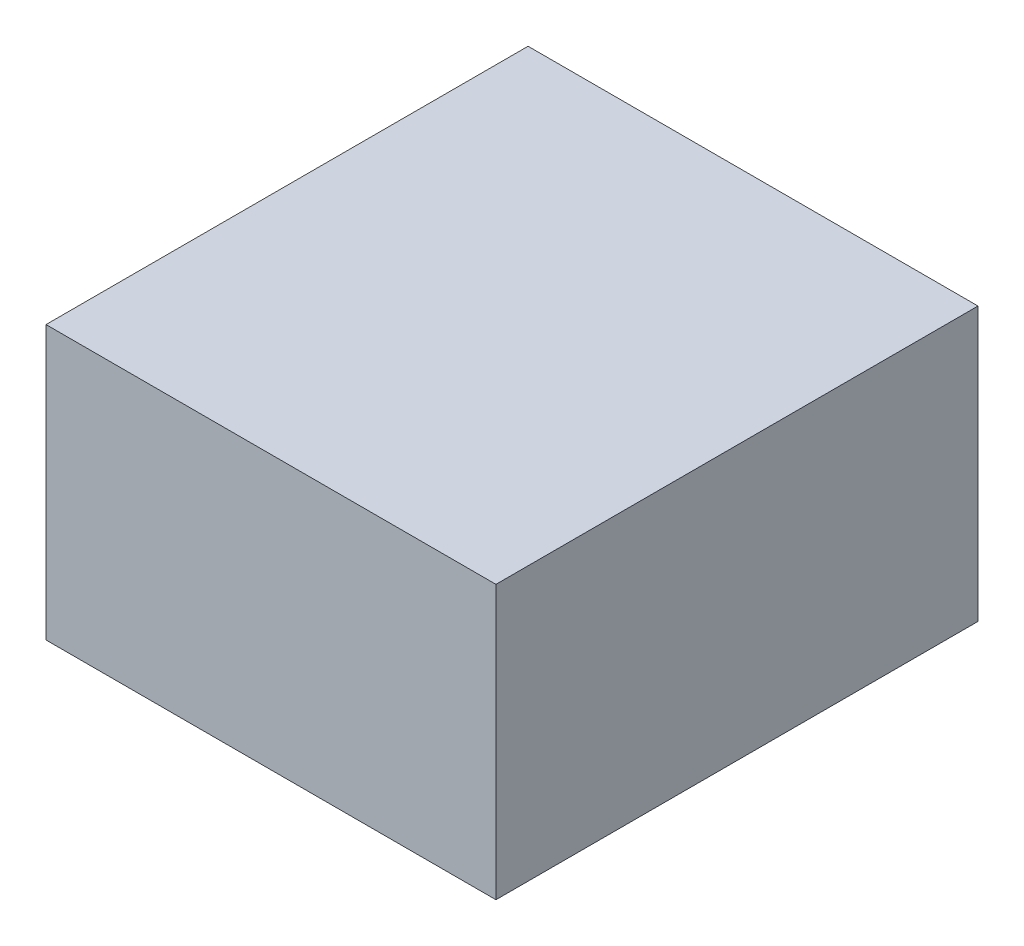
from build123d import *

# Parameters (mm, degrees)
SKETCH1_W           = 140
SKETCH1_H           = 150
BOSS_EXTRUDE1_DEPTH = 85
SKETCH2_W           = 26.921212121
SKETCH2_H           = 25.618572825
CUT_EXTRUDE1_DEPTH  = 20
SKETCH3_R           = 1.7525
CUT_EXTRUDE2_DEPTH  = 10


with BuildPart() as part:
    # Sketch1 → Boss-Extrude1 (new body)
    with BuildSketch(Plane(origin=(0, 0, 0), x_dir=(1, 0, 0), z_dir=(0, 1, 0))):
        Rectangle(SKETCH1_W, SKETCH1_H)
    extrude(amount=BOSS_EXTRUDE1_DEPTH)

    # Sketch2 → Cut-Extrude1 (cut)
    with BuildSketch(Plane.ZY.offset(70)):
        with Locations((36.962390029, 42.825659825)):
            Rectangle(SKETCH2_W, SKETCH2_H)
    extrude(amount=-CUT_EXTRUDE1_DEPTH, mode=Mode.SUBTRACT)

    # Sketch3 → Cut-Extrude2 (cut)
    with BuildSketch(Plane.ZY.offset(70)):
        with Locations((45, 6)):
            Circle(SKETCH3_R)
        with Locations((69, 79)):
            Circle(SKETCH3_R)
        with Locations((-69, 80)):
            Circle(SKETCH3_R)
        with Locations((-69, 16)):
            Circle(SKETCH3_R)
    extrude(amount=-CUT_EXTRUDE2_DEPTH, mode=Mode.SUBTRACT)


solid = part.part
